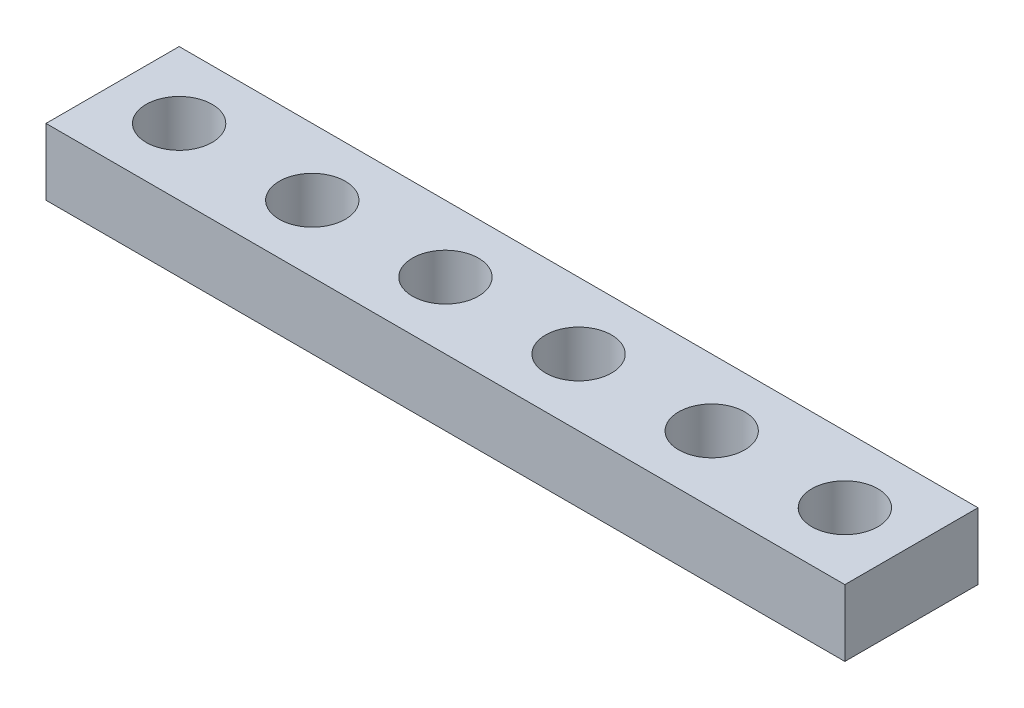
from build123d import *

# Parameters (mm, degrees)
SKETCH1_W           = 38.1
SKETCH1_H           = 6.35
BOSS_EXTRUDE1_DEPTH = 3.175
SKETCH2_R           = 1.5748
CUT_EXTRUDE1_DEPTH  = 4.175
LPATTERN1_COUNT     = 6
LPATTERN1_PITCH     = 6.35


with BuildPart() as part:
    # Sketch1 → Boss-Extrude1 (new body)
    with BuildSketch(Plane(origin=(0, 0, 0), x_dir=(1, 0, 0), z_dir=(0, 1, 0))):
        Rectangle(SKETCH1_W, SKETCH1_H)
    extrude(amount=BOSS_EXTRUDE1_DEPTH)

    # Sketch2 → Cut-Extrude1 (cut, through all)
    with BuildSketch(Plane(origin=(0, 3.175, 0), x_dir=(1, 0, 0), z_dir=(0, 1, 0))):
        with Locations((15.875, 0)):
            Circle(SKETCH2_R)
    cut_extrude1 = extrude(amount=-CUT_EXTRUDE1_DEPTH, mode=Mode.SUBTRACT)

    # LPattern1: Cut-Extrude1 ×6
    with Locations(*[(-i * LPATTERN1_PITCH, 0, 0) for i in range(1, LPATTERN1_COUNT)]):
        add(cut_extrude1, mode=Mode.SUBTRACT)


solid = part.part
